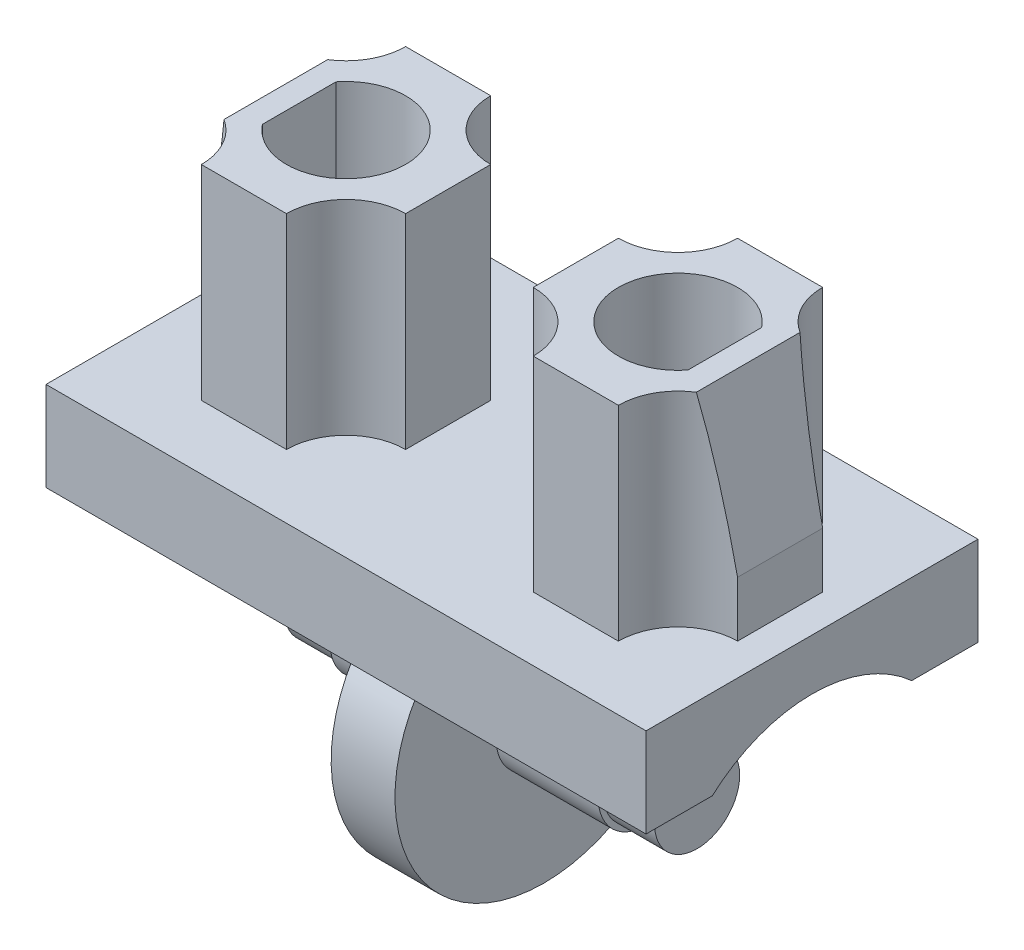
from build123d import *

# Parameters (mm, degrees)
BOSS_EXTRUDE1_DEPTH     = 7.05
SKETCH4_R               = 3.5
BOSS_EXTRUDE2_DEPTH     = 0.75
SKETCH5_R               = 1.125
BOSS_EXTRUDE3_DEPTH     = 2.4
SKETCH6_R               = 1
BOSS_EXTRUDE4_DEPTH     = 1.2
SKETCH7_R               = 1.125
BOSS_EXTRUDE5_DEPTH     = 2.4
SKETCH8_R               = 1
BOSS_EXTRUDE6_DEPTH     = 1.2
BOSS_EXTRUDE8_DEPTH     = 4.8
CUT_EXTRUDE1_DEPTH      = 4.8
CUT_EXTRUDE2_DEPTH      = 4.9
CUT_EXTRUDE2_DEPTH_BACK = 4.9


with BuildPart() as part:
    # Sketch2 → Boss-Extrude1 (new body, symmetric)
    with BuildSketch(Plane(origin=(0, 0, 0), x_dir=(0, 0, -1), z_dir=(1, 0, 0))):
        with BuildLine():
            ThreePointArc((-2.343074903, 2.6), (0, 3.5), (2.343074903, 2.6))
            Line((2.343074903, 2.6), (3.9, 2.6))
            Line((3.9, 2.6), (3.9, 4.7))
            Line((3.9, 4.7), (-3.9, 4.7))
            Line((-3.9, 4.7), (-3.9, 2.6))
            Line((-3.9, 2.6), (-2.343074903, 2.6))
        make_face()
    extrude(amount=BOSS_EXTRUDE1_DEPTH, both=True)

    # Sketch4 → Boss-Extrude2 (add, symmetric)
    with BuildSketch(Plane(origin=(0, 0, 0), x_dir=(0, 0, -1), z_dir=(1, 0, 0))):
        Circle(SKETCH4_R)
    extrude(amount=BOSS_EXTRUDE2_DEPTH, both=True)

    # Sketch5 → Boss-Extrude3 (add)
    with BuildSketch(Plane(origin=(0.75, 0, 0), x_dir=(0, 0, -1), z_dir=(1, 0, 0))):
        Circle(SKETCH5_R)
    extrude(amount=BOSS_EXTRUDE3_DEPTH)

    # Sketch6 → Boss-Extrude4 (add)
    with BuildSketch(Plane(origin=(3.15, 0, 0), x_dir=(0, 0, -1), z_dir=(1, 0, 0))):
        Circle(SKETCH6_R)
    extrude(amount=BOSS_EXTRUDE4_DEPTH)

    # Sketch7 → Boss-Extrude5 (add)
    with BuildSketch(Plane.ZY.offset(0.75)):
        Circle(SKETCH7_R)
    extrude(amount=BOSS_EXTRUDE5_DEPTH)

    # Sketch8 → Boss-Extrude6 (add)
    with BuildSketch(Plane.ZY.offset(3.15)):
        Circle(SKETCH8_R)
    extrude(amount=BOSS_EXTRUDE6_DEPTH)

    # Sketch9 → Boss-Extrude8 (add)
    with BuildSketch(Plane(origin=(0, 4.7, 0), x_dir=(1, 0, 0), z_dir=(0, 1, 0))):
        with BuildLine():
            Line((2.9, -2.4), (4.9, -2.4))
            ThreePointArc((4.9, -2.4), (5.310050506, -1.410050506), (6.3, -1))
            Line((6.3, -1), (6.3, 1))
            ThreePointArc((6.3, 1), (5.310050506, 1.410050506), (4.9, 2.4))
            Line((4.9, 2.4), (2.9, 2.4))
            ThreePointArc((2.9, 2.4), (2.489949494, 1.410050506), (1.5, 1))
            Line((1.5, 1), (1.5, -1))
            ThreePointArc((1.5, -1), (2.489949494, -1.410050506), (2.9, -2.4))
        make_face()
        with BuildLine():
            Line((-6.3, -1), (-6.3, 1))
            ThreePointArc((-6.3, 1), (-5.310050506, 1.410050506), (-4.9, 2.4))
            Line((-4.9, 2.4), (-2.9, 2.4))
            ThreePointArc((-2.9, 2.4), (-2.489949494, 1.410050506), (-1.5, 1))
            Line((-1.5, 1), (-1.5, -1))
            ThreePointArc((-1.5, -1), (-2.489949494, -1.410050506), (-2.9, -2.4))
            Line((-2.9, -2.4), (-4.9, -2.4))
            ThreePointArc((-4.9, -2.4), (-5.310050506, -1.410050506), (-6.3, -1))
        make_face()
    extrude(amount=BOSS_EXTRUDE8_DEPTH)

    # Sketch10 → Cut-Extrude1 (cut)
    with BuildSketch(Plane(origin=(0, 9.5, 0), x_dir=(1, 0, 0), z_dir=(0, 1, 0))):
        with BuildLine():
            Line((5, 0.866025404), (5, -0.866025404))
            ThreePointArc((5, -0.866025404), (2.5, 0), (5, 0.866025404))
        make_face()
        with BuildLine():
            Line((-5, 0.866025404), (-5, -0.866025404))
            ThreePointArc((-5, -0.866025404), (-2.5, 0), (-5, 0.866025404))
        make_face()
    extrude(amount=-CUT_EXTRUDE1_DEPTH, mode=Mode.SUBTRACT)

    # Sketch12 → Cut-Extrude2 (cut, two sides)
    with BuildSketch(Plane.XY) as cut_extrude2_sk:
        Polygon((5.55, 9.5), (6.3, 9.5), (6.3, 6), align=None)
        Polygon((-6.3, 6), (-5.55, 9.5), (-6.3, 9.5), align=None)
    extrude(amount=CUT_EXTRUDE2_DEPTH, mode=Mode.SUBTRACT)
    extrude(cut_extrude2_sk.sketch, amount=-CUT_EXTRUDE2_DEPTH_BACK, mode=Mode.SUBTRACT)


solid = part.part
